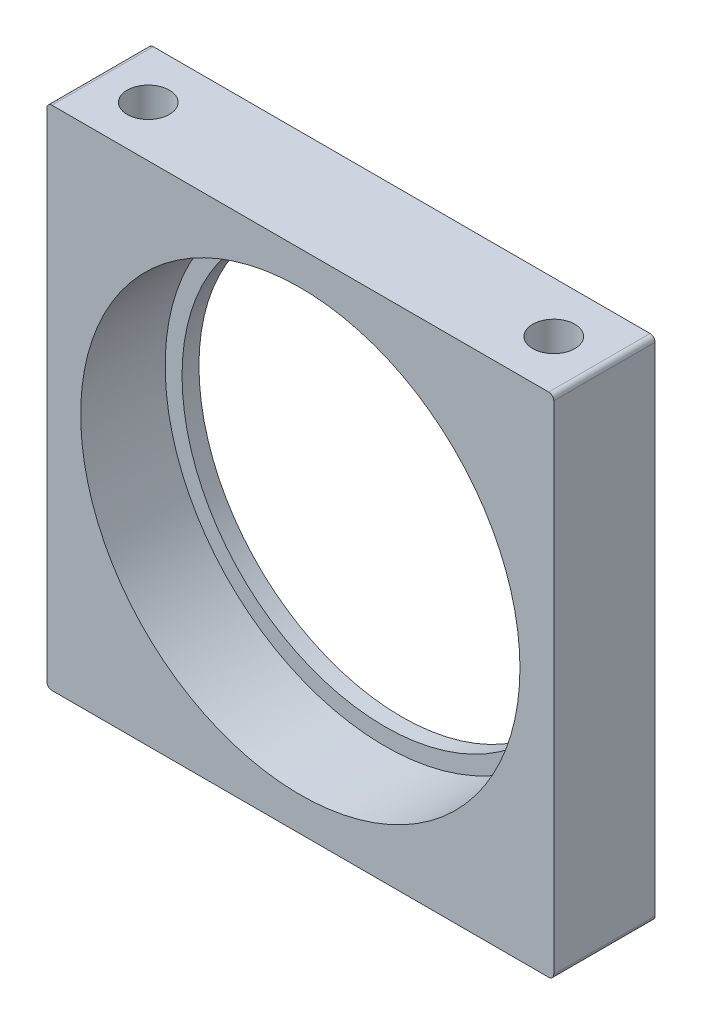
from build123d import *

# Parameters (mm, degrees)
ESQUISSE1_W                                   = 30
ESQUISSE1_H                                   = 30
ESQUISSE1_R                                   = 12
BOSS_EXTRU_1_DEPTH                            = 6
ESQUISSE2_R                                   = 13
ENL_V_MAT_EXTRU_1_DEPTH                       = 5
TROU_POUR_TARAUDAGE_POUR_TROU_TARAUD_M3_D     = 2.5
TROU_POUR_TARAUDAGE_POUR_TROU_TARAUD_M3_DEPTH = 6
TROU_POUR_TARAUDAGE_POUR_TROU_TARAUD_M3_TIP   = 0.751075774
TROU_POUR_TARAUDAGE_POUR_TROU_TARAUD_2_D      = 2.5
TROU_POUR_TARAUDAGE_POUR_TROU_TARAUD_2_DEPTH  = 6
TROU_POUR_TARAUDAGE_POUR_TROU_TARAUD_2_TIP    = 0.751075774
CONG_1_R                                      = 0.3


with BuildPart() as part:
    # Esquisse1 → Boss.-Extru.1 (new body)
    with BuildSketch(Plane.XY):
        with Locations((15, 15)):
            Rectangle(ESQUISSE1_W, ESQUISSE1_H)
        with Locations((15, 15)):
            Circle(ESQUISSE1_R, mode=Mode.SUBTRACT)
    extrude(amount=BOSS_EXTRU_1_DEPTH)

    # Esquisse2 → Enlèv. mat.-Extru.1 (cut)
    with BuildSketch(Plane.XY.offset(6)):
        with Locations((15, 15)):
            Circle(ESQUISSE2_R)
    extrude(amount=-ENL_V_MAT_EXTRU_1_DEPTH, mode=Mode.SUBTRACT)

    # Trou pour taraudage pour trou taraud_ M3
    with Locations(Plane(origin=(0, 30, 0), x_dir=(1, 0, 0), z_dir=(0, 1, 0))):
        with Locations((3, -3), (27, -3)):
            Hole(TROU_POUR_TARAUDAGE_POUR_TROU_TARAUD_M3_D / 2, depth=TROU_POUR_TARAUDAGE_POUR_TROU_TARAUD_M3_DEPTH)
            with Locations((0, 0, -(TROU_POUR_TARAUDAGE_POUR_TROU_TARAUD_M3_DEPTH + TROU_POUR_TARAUDAGE_POUR_TROU_TARAUD_M3_TIP / 2))):  # 118° drill point
                Cone(0, TROU_POUR_TARAUDAGE_POUR_TROU_TARAUD_M3_D / 2, TROU_POUR_TARAUDAGE_POUR_TROU_TARAUD_M3_TIP, mode=Mode.SUBTRACT)

    # Trou pour taraudage pour trou taraud 2
    with Locations(Plane(origin=(0, 0, 0), x_dir=(-1, 0, 0), z_dir=(0, -1, 0))):
        with Locations((-3, -3), (-27, -3)):
            Hole(TROU_POUR_TARAUDAGE_POUR_TROU_TARAUD_2_D / 2, depth=TROU_POUR_TARAUDAGE_POUR_TROU_TARAUD_2_DEPTH)
            with Locations((0, 0, -(TROU_POUR_TARAUDAGE_POUR_TROU_TARAUD_2_DEPTH + TROU_POUR_TARAUDAGE_POUR_TROU_TARAUD_2_TIP / 2))):  # 118° drill point
                Cone(0, TROU_POUR_TARAUDAGE_POUR_TROU_TARAUD_2_D / 2, TROU_POUR_TARAUDAGE_POUR_TROU_TARAUD_2_TIP, mode=Mode.SUBTRACT)

    # Congé1
    cong_1_edges = [part.edges().sort_by_distance(p)[0] for p in [
        (0, 30, 3),
        (30, 30, 3),
        (30, 0, 3),
        (0, 0, 3),
    ]]
    fillet(cong_1_edges, radius=CONG_1_R)


solid = part.part
